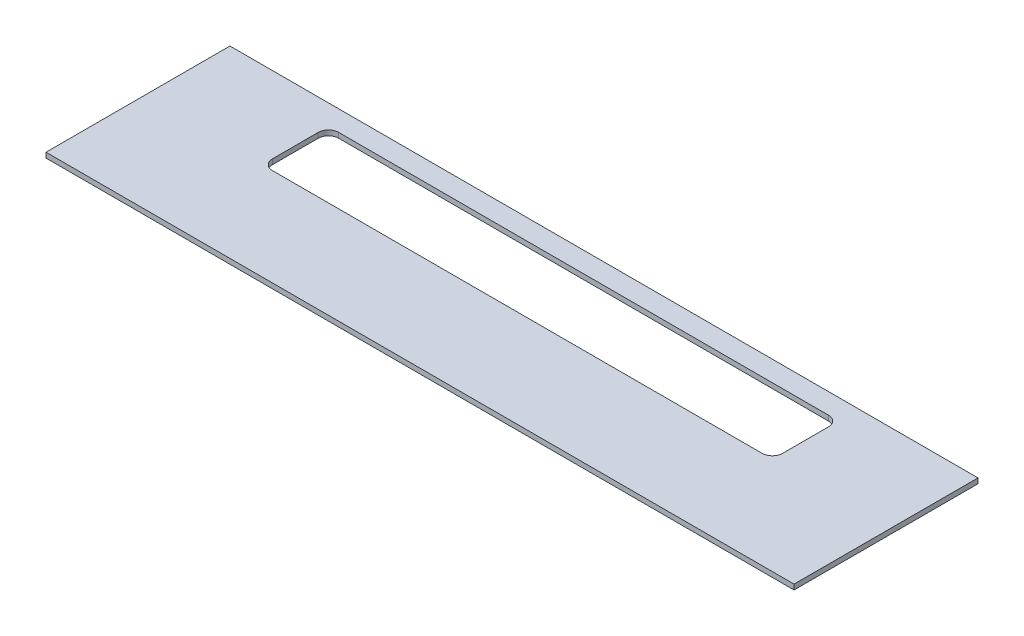
from build123d import *

# Parameters (mm, degrees)
SKETCH1_W           = 232.41
SKETCH1_H           = 57.15
BOSS_EXTRUDE1_DEPTH = 1.5875
SKETCH2_W           = 158.496
SKETCH2_H           = 20.574
CUT_EXTRUDE1_DEPTH  = 2.5875
FILLET1_R           = 3.175


with BuildPart() as part:
    # Sketch1 → Boss-Extrude1 (new body)
    with BuildSketch(Plane(origin=(0, 0, 0), x_dir=(1, 0, 0), z_dir=(0, 1, 0))):
        Rectangle(SKETCH1_W, SKETCH1_H)
    extrude(amount=BOSS_EXTRUDE1_DEPTH)

    # Sketch2 → Cut-Extrude1 (cut, through all)
    with BuildSketch(Plane(origin=(0, 1.5875, 0), x_dir=(1, 0, 0), z_dir=(0, 1, 0))):
        with Locations((0, 11.938)):
            Rectangle(SKETCH2_W, SKETCH2_H)
    extrude(amount=-CUT_EXTRUDE1_DEPTH, mode=Mode.SUBTRACT)

    # Fillet1
    fillet1_edges = [part.edges().sort_by_distance(p)[0] for p in [
        (-79.248, 0.79375, -1.651),
        (-79.248, 0.79375, -22.225),
        (79.248, 0.79375, -22.225),
        (79.248, 0.79375, -1.651),
    ]]
    fillet(fillet1_edges, radius=FILLET1_R)


solid = part.part
